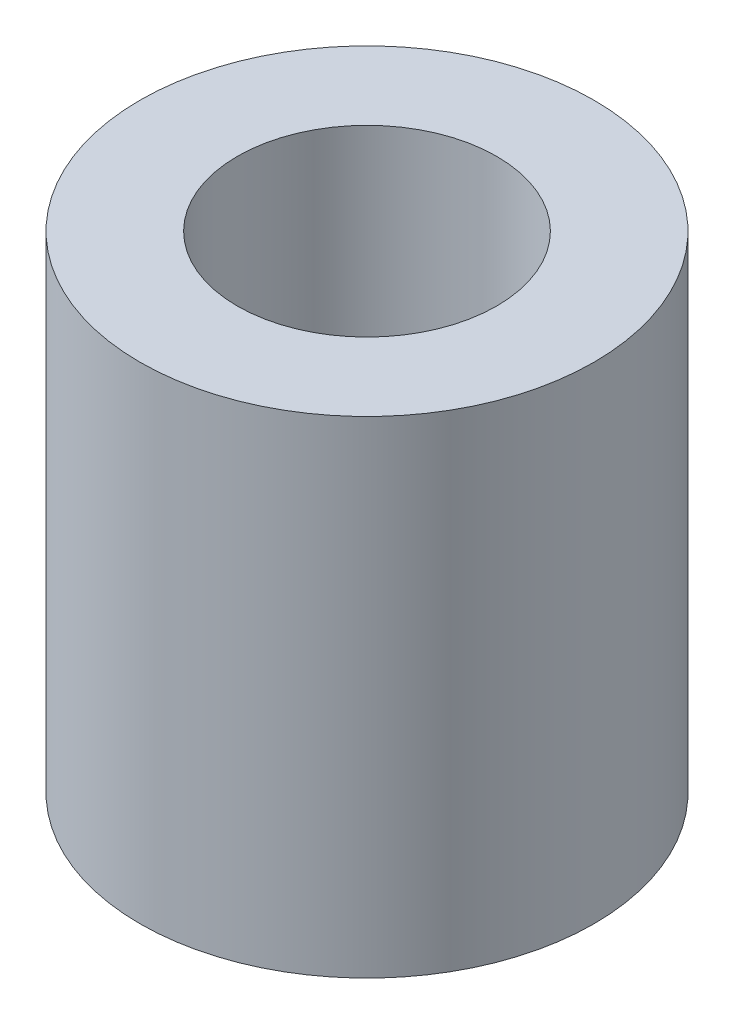
from build123d import *

# Parameters (mm, degrees)
SKETCH1_R           = 7
SKETCH1_R_2         = 4
BOSS_EXTRUDE1_DEPTH = 15


with BuildPart() as part:
    # Sketch1 → Boss-Extrude1 (new body)
    with BuildSketch(Plane(origin=(0, 0, 0), x_dir=(1, 0, 0), z_dir=(0, 1, 0))):
        with Locations(Location((0, 0, 0), (0, 0, 270))):  # turned: the seam where the file's is
            Circle(SKETCH1_R)
        with Locations(Location((0, 0, 0), (0, 0, 270))):  # turned: the seam where the file's is
            Circle(SKETCH1_R_2, mode=Mode.SUBTRACT)
    extrude(amount=BOSS_EXTRUDE1_DEPTH)


solid = part.part
